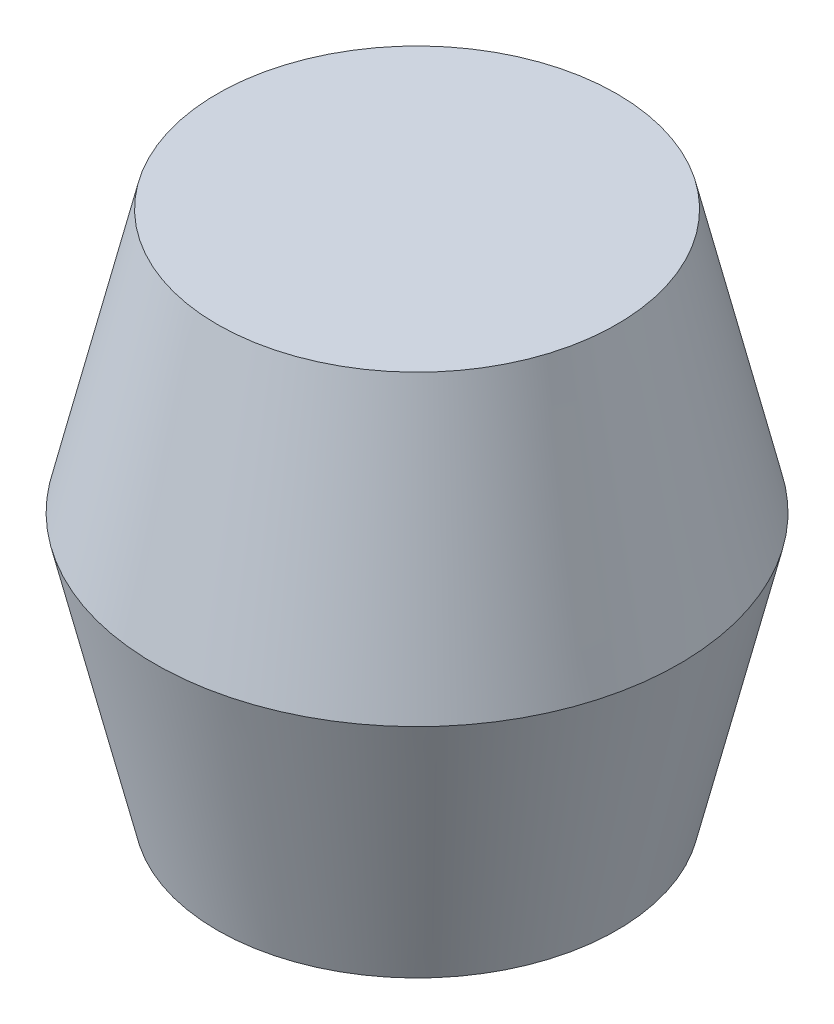
from build123d import *


with BuildPart() as part:
    # Sketch1 → Revolve1 (revolve)
    with BuildSketch(Plane(origin=(0, 0, 0), x_dir=(0, 0, -1), z_dir=(1, 0, 0))):
        Polygon((0, 6.35), (1.1811, 6.35), (1.1811, 0), (3.0226, 0), (3.96875, 3.9624), (3.0226, 7.9375), (0, 7.9375), align=None)
    revolve(axis=Axis((0, 0, 0), (0, 1, 0)))


solid = part.part
